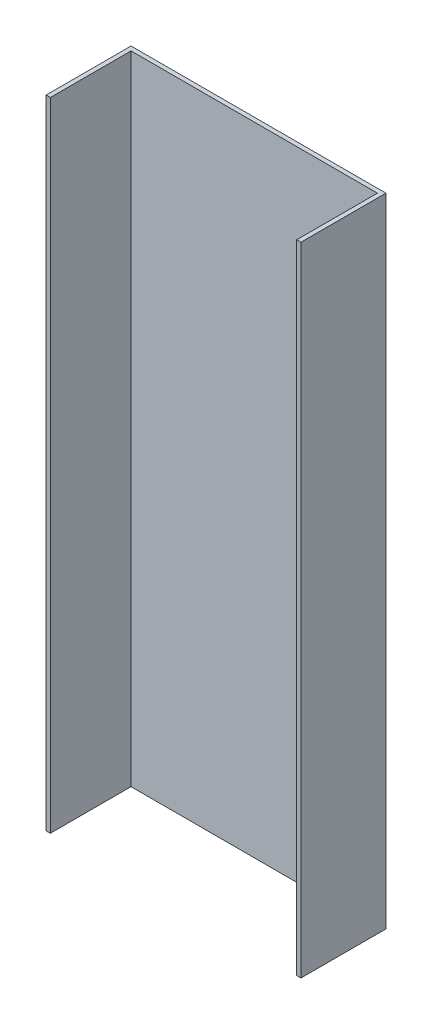
from build123d import *

# Parameters (mm, degrees)
SKETCH2_W           = 600
SKETCH2_H           = 1500
BOSS_EXTRUDE1_DEPTH = 10
SKETCH5_W           = 10
SKETCH5_H           = 1500
EXTRUDE_THIN2_DEPTH = 200


with BuildPart() as part:
    # Sketch2 → Boss-Extrude1 (new body)
    with BuildSketch(Plane.XY):
        Rectangle(SKETCH2_W, SKETCH2_H)
    extrude(amount=BOSS_EXTRUDE1_DEPTH)

    # Sketch5 → Extrude-Thin2 (add)
    with BuildSketch(Plane(origin=(0, 0, 0), x_dir=(-1, 0, 0), z_dir=(0, 0, -1))):
        with Locations((-295, 0)):
            Rectangle(SKETCH5_W, SKETCH5_H)
        with Locations((295, 0)):
            Rectangle(SKETCH5_W, SKETCH5_H)
    extrude(amount=-EXTRUDE_THIN2_DEPTH)


solid = part.part
